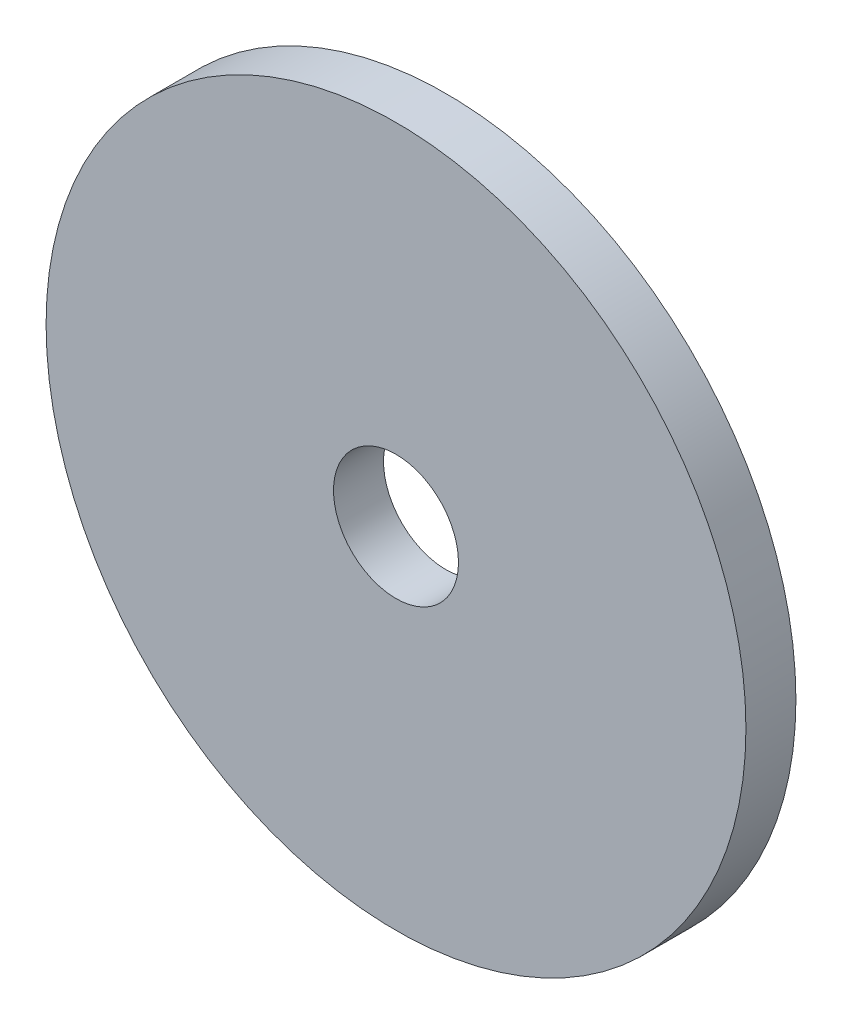
from build123d import *

# Parameters (mm, degrees)
SKETCH1_R           = 14
SKETCH1_R_2         = 2.5
BOSS_EXTRUDE1_DEPTH = 2


with BuildPart() as part:
    # Sketch1 → Boss-Extrude1 (new body)
    with BuildSketch(Plane.XY):
        Circle(SKETCH1_R)
        Circle(SKETCH1_R_2, mode=Mode.SUBTRACT)
    extrude(amount=BOSS_EXTRUDE1_DEPTH)


solid = part.part
